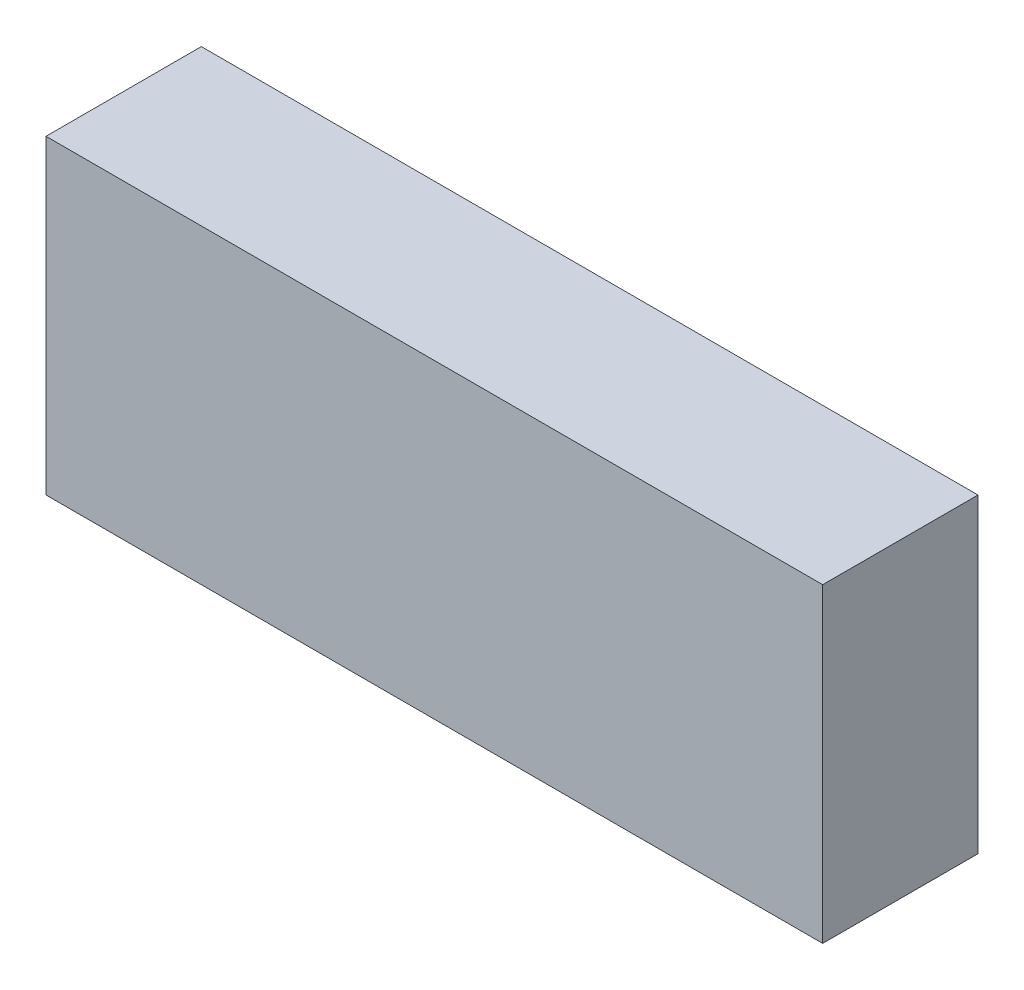
from build123d import *

# Parameters (mm, degrees)
ESQUISSE1_W        = 45
ESQUISSE1_H        = 18
BOSS_EXTRU_1_DEPTH = 9


with BuildPart() as part:
    # Esquisse1 → Boss.-Extru.1 (new body)
    with BuildSketch(Plane.XY):
        with Locations((22.5, 9)):
            Rectangle(ESQUISSE1_W, ESQUISSE1_H)
    extrude(amount=BOSS_EXTRU_1_DEPTH)


solid = part.part
